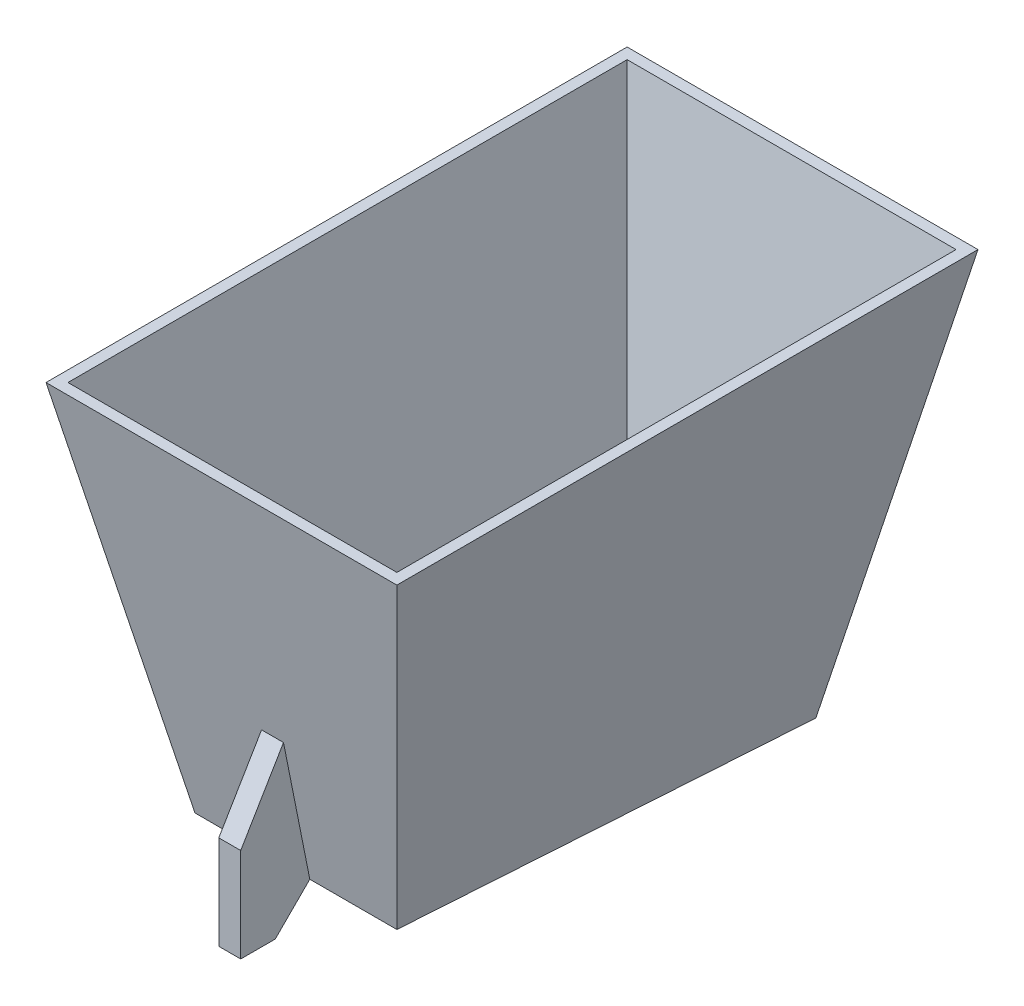
from build123d import *

# Parameters (mm, degrees)
SKETCH1_W             = 203.2
SKETCH1_H             = 336.55
BOSS_EXTRUDE4_DEPTH   = 254
BOSS_EXTRUDE4_TAPER   = 11.3
SKETCH3_W             = 190.5
SKETCH3_H             = 323.85
CUT_EXTRUDE1_DEPTH    = 247.65
CUT_EXTRUDE1_TAPER    = 11.25
CUT_EXTRUDE13_DEPTH   = 254
BOSS_EXTRUDE6_START   = 102.7176
BOSS_EXTRUDE6_DEPTH   = 12.7
BOSS_EXTRUDE7_DEPTH   = 6.35
BODY_MOVE_COPY1_ANGLE = 180
BODY_MOVE_COPY2_ANGLE = 180


with BuildPart() as part:
    # Sketch1 → Boss-Extrude4 (new body)
    with BuildSketch(Plane(origin=(0, 0, 0), x_dir=(1, 0, 0), z_dir=(0, 1, 0))):
        with Locations((-183.252356021, -34.226832461)):
            Rectangle(SKETCH1_W, SKETCH1_H)
    extrude(amount=BOSS_EXTRUDE4_DEPTH, taper=BOSS_EXTRUDE4_TAPER)

    # Sketch3 → Cut-Extrude1 (cut)
    with BuildSketch(Plane.XZ):
        with Locations((-183.252356021, 34.226832461)):
            Rectangle(SKETCH3_W, SKETCH3_H)
    extrude(amount=-CUT_EXTRUDE1_DEPTH, taper=CUT_EXTRUDE1_TAPER, mode=Mode.SUBTRACT)

    # Sketch15 → Cut-Extrude13 (cut)
    with BuildSketch(Plane(origin=(-294, 0, 0), x_dir=(0, 0, -1), z_dir=(1, 0, 0))):
        Polygon((83.293959244, 254), (-151.747624165, 254), (-159.360755409, 215.9), (87.100524866, 234.95), align=None)
    extrude(amount=CUT_EXTRUDE13_DEPTH, mode=Mode.SUBTRACT)

    # Sketch21 → Boss-Extrude6 (add)
    with BuildSketch(Plane(origin=(-294, 0, 0), x_dir=(0, 0, -1), z_dir=(1, 0, 0)).offset(BOSS_EXTRUDE6_START)):
        Polygon((-174.587017898, 139.7), (-199.360755409, 181.473734378), (-199.360755409, 235.9), (-179.360755409, 235.9), (-179.360755409, 215.9), (-159.360755409, 215.9), align=None)
        Polygon((-179.360755409, 235.9), (-179.360755409, 215.9), (-159.360755409, 215.9), align=None)
    extrude(amount=BOSS_EXTRUDE6_DEPTH)

    # Sketch22 → Boss-Extrude7 (add)
    with BuildSketch(Plane(origin=(0, 226.862283718, 17.535113426), x_dir=(1, 0, 0), z_dir=(0, 0.997026131, 0.077064226))):
        Polygon((-237.904713348, 104.947739163), (-241.71127897, -142.248670954), (-124.793433072, -142.248670954), (-128.599998694, 104.947739163), align=None)
    extrude(amount=-BOSS_EXTRUDE7_DEPTH)


with BuildPart() as part_1:
    # Body-Move/Copy1: moved
    add(part.part.rotate(Axis((0, 117.95, 34.226832461), (1, 0, 0)), BODY_MOVE_COPY1_ANGLE))


with BuildPart() as part_2:
    # Body-Move/Copy2: moved
    add(part_1.part.rotate(Axis((-183.252356021, 0, 34.226832461), (0, 1, 0)), BODY_MOVE_COPY2_ANGLE))


solid = part_2.part
